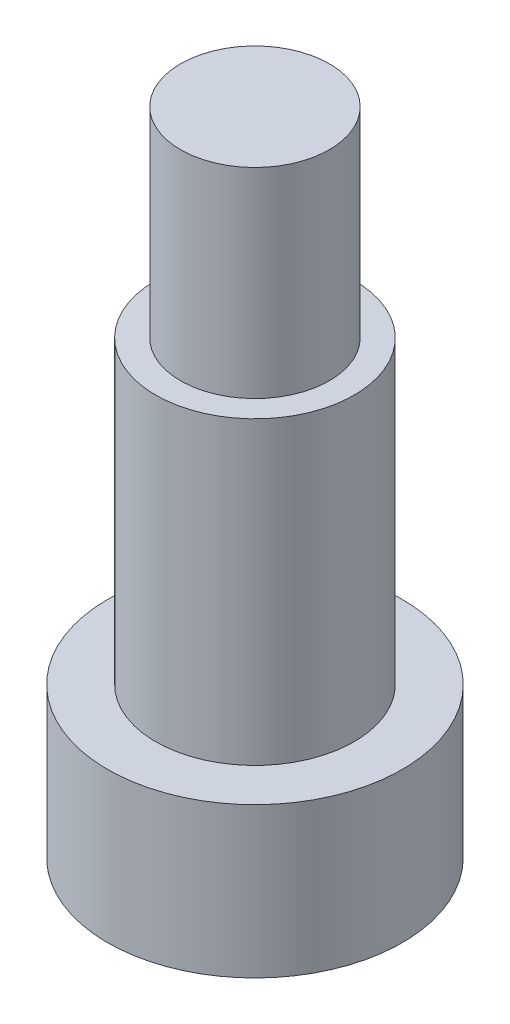
from build123d import *


with BuildPart() as part:
    # Sketch1 → Revolve1 (revolve)
    with BuildSketch(Plane.XY):
        Polygon((0, 0), (4.6736, 0), (4.6736, 4.7625), (3.1496, 4.7625), (3.1496, 14.2875), (2.3622, 14.2875), (2.3622, 20.6375), (0, 20.6375), align=None)
    revolve(axis=Axis((0, 31.295296656, 0), (0, -1, 0)))


solid = part.part
